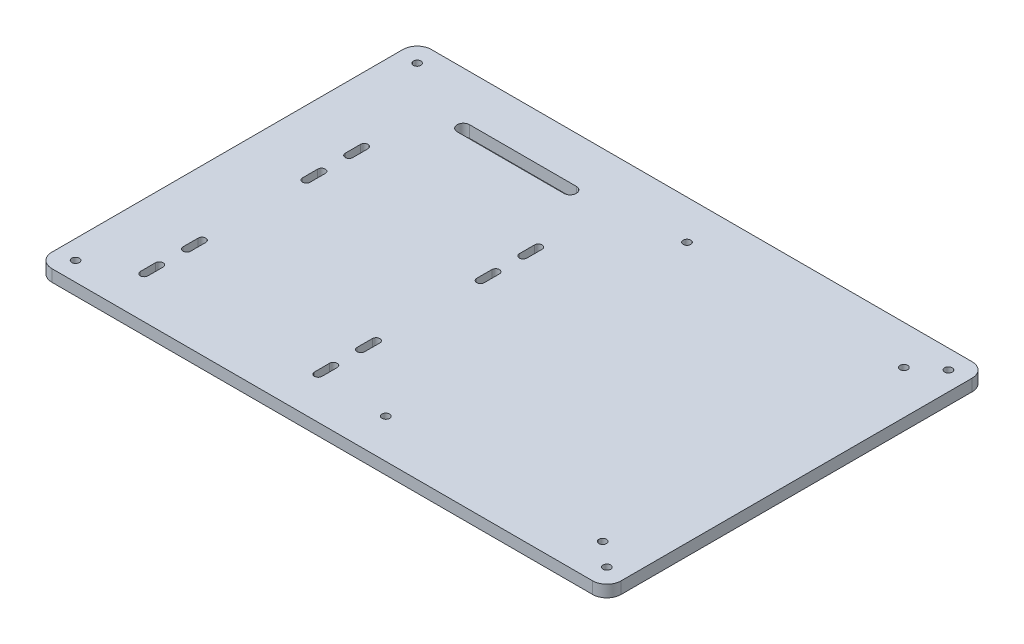
from build123d import *

# Parameters (mm, degrees)
SKETCH1_W           = 240
SKETCH1_H           = 160
BOSS_EXTRUDE1_DEPTH = 5
SKETCH2_R           = 1.6
CUT_EXTRUDE1_DEPTH  = 5
FILLET1_R           = 6


with BuildPart() as part:
    # Sketch1 → Boss-Extrude1 (new body)
    with BuildSketch(Plane(origin=(0, 0, 0), x_dir=(1, 0, 0), z_dir=(0, 1, 0))):
        Rectangle(SKETCH1_W, SKETCH1_H)
    extrude(amount=BOSS_EXTRUDE1_DEPTH)

    # Sketch2 → Cut-Extrude1 (cut)
    with BuildSketch(Plane(origin=(0, 5, 0), x_dir=(1, 0, 0), z_dir=(0, 1, 0))):
        with Locations((-112, 72)):
            Circle(SKETCH2_R)
        with Locations((-112, -72)):
            Circle(SKETCH2_R)
        with Locations((112, 72)):
            Circle(SKETCH2_R)
        with Locations((112, -72)):
            Circle(SKETCH2_R)
        with Locations((10.28, 63.5)):
            Circle(SKETCH2_R)
        with Locations((101.72, 63.5)):
            Circle(SKETCH2_R)
        with Locations((101.72, -63.5)):
            Circle(SKETCH2_R)
        with Locations((10.28, -63.5)):
            Circle(SKETCH2_R)
        with BuildLine():
            Line((-94.3, 30.4), (-94.3, 24))
            ThreePointArc((-94.3, 24), (-92.7, 22.4), (-91.1, 24))
            Line((-91.1, 24), (-91.1, 30.4))
            ThreePointArc((-91.1, 30.4), (-92.7, 32), (-94.3, 30.4))
        make_face()
        with BuildLine():
            Line((-94.3, 12.4), (-94.3, 6))
            ThreePointArc((-94.3, 6), (-92.7, 4.4), (-91.1, 6))
            Line((-91.1, 6), (-91.1, 12.4))
            ThreePointArc((-91.1, 12.4), (-92.7, 14), (-94.3, 12.4))
        make_face()
        with BuildLine():
            Line((-20.9, 12.4), (-20.9, 6))
            ThreePointArc((-20.9, 6), (-19.3, 4.4), (-17.7, 6))
            Line((-17.7, 6), (-17.7, 12.4))
            ThreePointArc((-17.7, 12.4), (-19.3, 14), (-20.9, 12.4))
        make_face()
        with BuildLine():
            Line((-20.9, 30.4), (-20.9, 24))
            ThreePointArc((-20.9, 24), (-19.3, 22.4), (-17.7, 24))
            Line((-17.7, 24), (-17.7, 30.4))
            ThreePointArc((-17.7, 30.4), (-19.3, 32), (-20.9, 30.4))
        make_face()
        with BuildLine():
            Line((-94.3, -62.4), (-94.3, -56))
            ThreePointArc((-94.3, -56), (-92.7, -54.4), (-91.1, -56))
            Line((-91.1, -56), (-91.1, -62.4))
            ThreePointArc((-91.1, -62.4), (-92.7, -64), (-94.3, -62.4))
        make_face()
        with BuildLine():
            Line((-91.1, -44.4), (-91.1, -38))
            ThreePointArc((-91.1, -38), (-92.7, -36.4), (-94.3, -38))
            Line((-94.3, -38), (-94.3, -44.4))
            ThreePointArc((-94.3, -44.4), (-92.7, -46), (-91.1, -44.4))
        make_face()
        with BuildLine():
            Line((-78.5, 55.4), (-33.5, 55.4))
            ThreePointArc((-33.5, 55.4), (-30.9, 58), (-33.5, 60.6))
            Line((-33.5, 60.6), (-78.5, 60.6))
            ThreePointArc((-78.5, 60.6), (-81.1, 58), (-78.5, 55.4))
        make_face()
        with BuildLine():
            Line((-17.7, -62.4), (-17.7, -56))
            ThreePointArc((-17.7, -56), (-19.3, -54.4), (-20.9, -56))
            Line((-20.9, -56), (-20.9, -62.4))
            ThreePointArc((-20.9, -62.4), (-19.3, -64), (-17.7, -62.4))
        make_face()
        with BuildLine():
            Line((-20.9, -44.4), (-20.9, -38))
            ThreePointArc((-20.9, -38), (-19.3, -36.4), (-17.7, -38))
            Line((-17.7, -38), (-17.7, -44.4))
            ThreePointArc((-17.7, -44.4), (-19.3, -46), (-20.9, -44.4))
        make_face()
    extrude(amount=-CUT_EXTRUDE1_DEPTH, mode=Mode.SUBTRACT)

    # Fillet1
    fillet1_edges = [part.edges().sort_by_distance(p)[0] for p in [
        (120, 2.5, 80),
        (-120, 2.5, 80),
        (-120, 2.5, -80),
        (120, 2.5, -80),
    ]]
    fillet(fillet1_edges, radius=FILLET1_R)


solid = part.part
